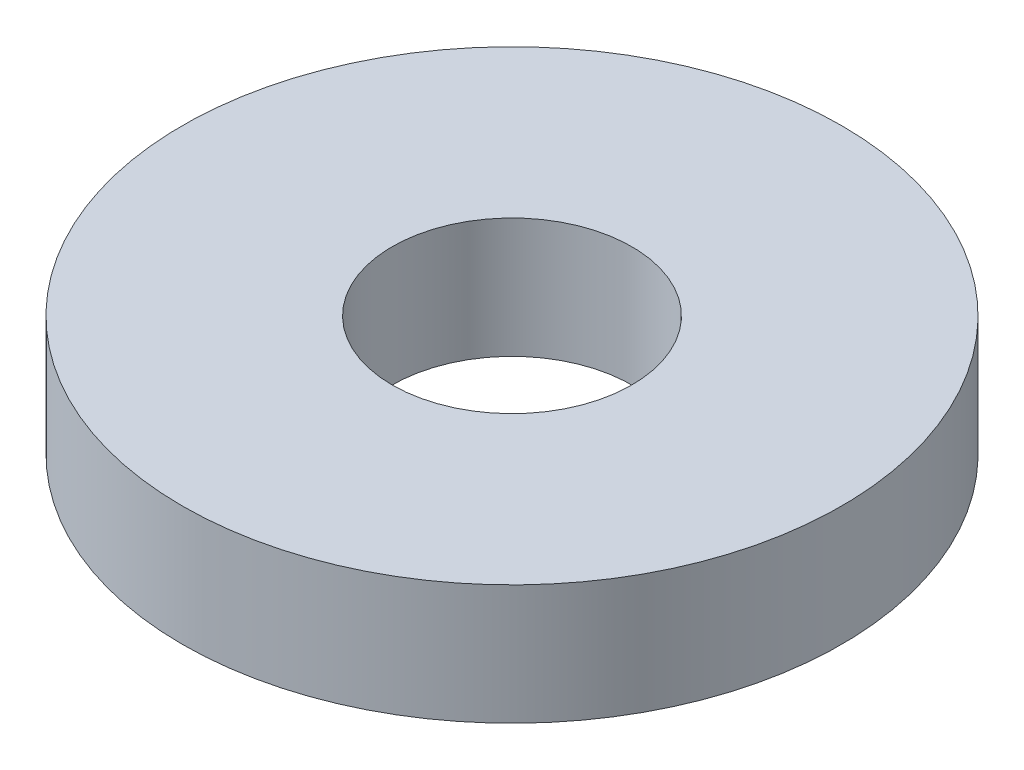
from build123d import *

# Parameters (mm, degrees)
SKETCH1_R           = 27.5
SKETCH1_R_2         = 10
BOSS_EXTRUDE1_DEPTH = 10


with BuildPart() as part:
    # Sketch1 → Boss-Extrude1 (new body)
    with BuildSketch(Plane(origin=(0, 0, 0), x_dir=(1, 0, 0), z_dir=(0, 1, 0))):
        Circle(SKETCH1_R)
        Circle(SKETCH1_R_2, mode=Mode.SUBTRACT)
    extrude(amount=BOSS_EXTRUDE1_DEPTH)


solid = part.part
